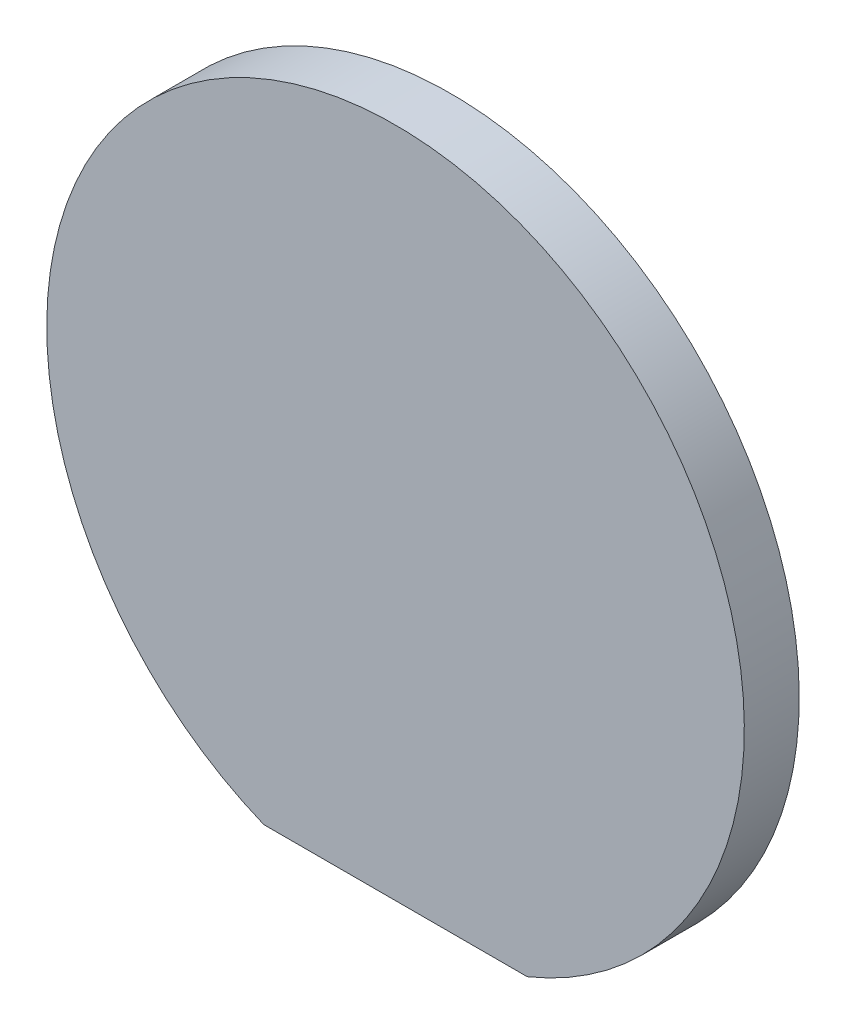
from build123d import *

# Parameters (mm, degrees)
SKETCH_1_R          = 6.35
EXTRUDE_1_DEPTH     = 1
SKETCH_2_W          = 13.590670976
SKETCH_2_H          = 1.925848739
CUT_EXTRUDE_1_DEPTH = 2


with BuildPart() as part:
    # 草图1 → 凸台-拉伸1 (new body)
    with BuildSketch(Plane.XY):
        Circle(SKETCH_1_R)
    extrude(amount=EXTRUDE_1_DEPTH)

    # 草图2 → 切除-拉伸1 (cut, through all)
    with BuildSketch(Plane.XY.offset(1)):
        with Locations((0.907997414, -6.84292437)):
            Rectangle(SKETCH_2_W, SKETCH_2_H)
    extrude(amount=-CUT_EXTRUDE_1_DEPTH, mode=Mode.SUBTRACT)


solid = part.part
